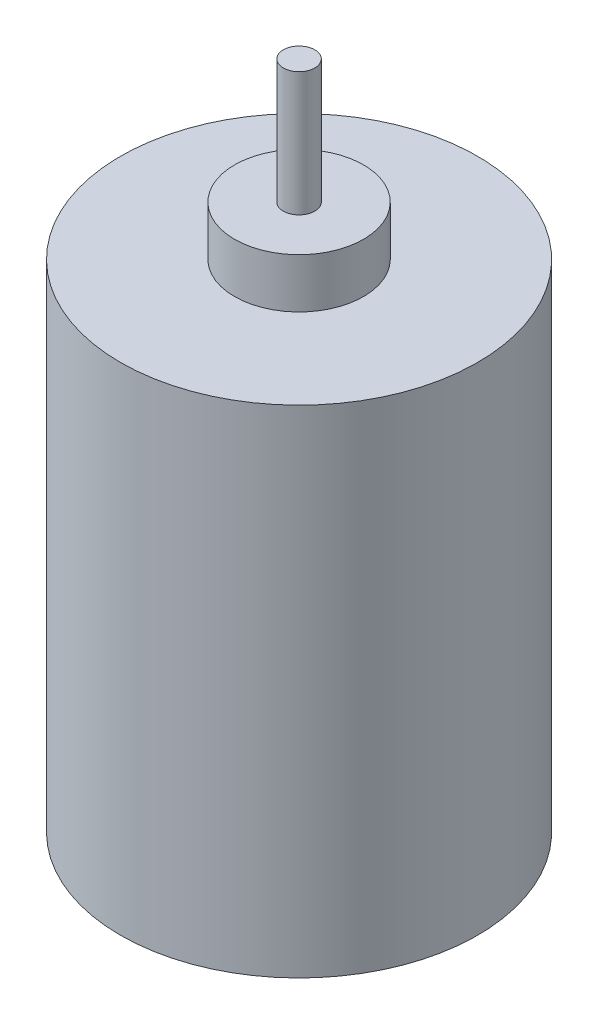
from build123d import *

# Parameters (mm, degrees)
SKETCH1_R           = 18
BOSS_EXTRUDE1_DEPTH = 50
BOSS_EXTRUDE2_START = 50
SKETCH2_R           = 6.5
BOSS_EXTRUDE2_DEPTH = 5
BOSS_EXTRUDE3_START = 55
SKETCH3_R           = 1.5875
BOSS_EXTRUDE3_DEPTH = 12.5


with BuildPart() as part:
    # Sketch1 → Boss-Extrude1 (new body)
    with BuildSketch(Plane(origin=(0, 0, 0), x_dir=(1, 0, 0), z_dir=(0, 1, 0))):
        Circle(SKETCH1_R)
    extrude(amount=BOSS_EXTRUDE1_DEPTH)

    # Sketch2 → Boss-Extrude2 (add)
    with BuildSketch(Plane(origin=(0, 0, 0), x_dir=(1, 0, 0), z_dir=(0, 1, 0)).offset(BOSS_EXTRUDE2_START)):
        Circle(SKETCH2_R)
    extrude(amount=BOSS_EXTRUDE2_DEPTH)

    # Sketch3 → Boss-Extrude3 (add)
    with BuildSketch(Plane(origin=(0, 0, 0), x_dir=(1, 0, 0), z_dir=(0, 1, 0)).offset(BOSS_EXTRUDE3_START)):
        Circle(SKETCH3_R)
    extrude(amount=BOSS_EXTRUDE3_DEPTH)


solid = part.part
